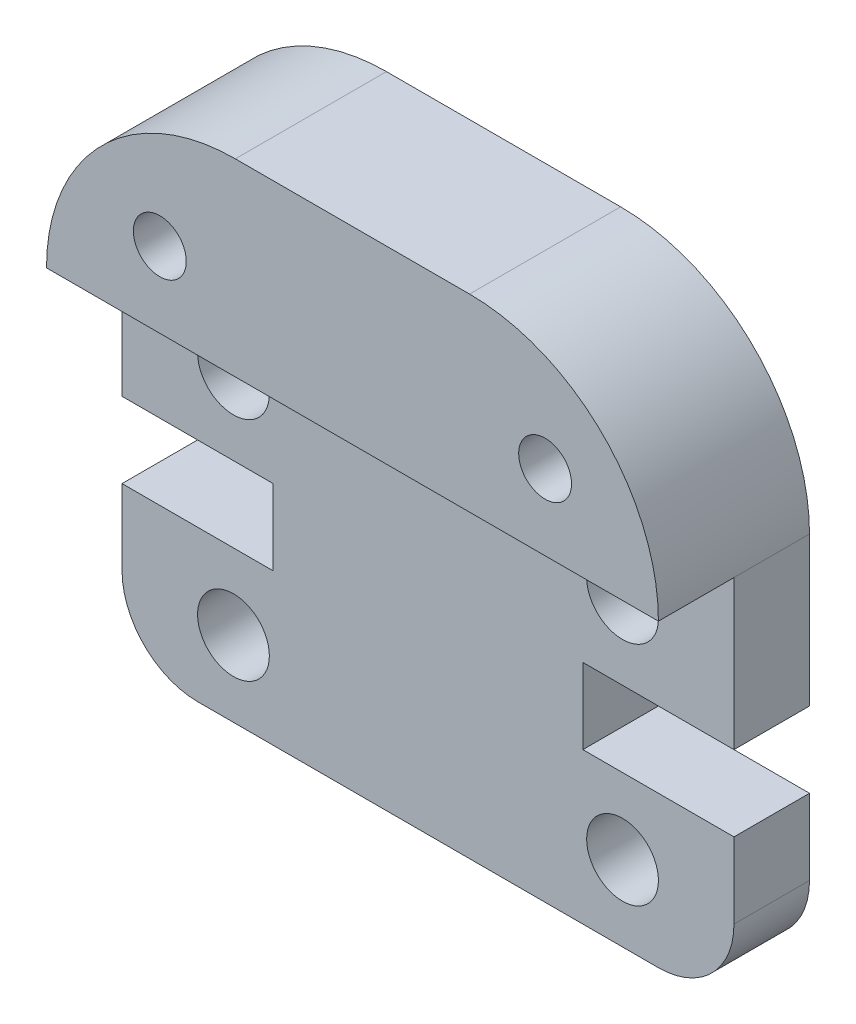
from build123d import *

# Parameters (mm, degrees)
SKETCH2_R           = 0.95
SKETCH2_R_2         = 0.7
BOSS_EXTRUDE1_DEPTH = 4
SKETCH3_W           = 16.2
SKETCH3_H           = 9.945
CUT_EXTRUDE2_DEPTH  = 2


with BuildPart() as part:
    # Sketch2 → Boss-Extrude1 (new body)
    with BuildSketch(Plane.XY):
        with BuildLine():
            Line((0, 9.945), (0, 6))
            Line((0, 6), (4, 6))
            Line((4, 6), (4, 4))
            Line((4, 4), (0, 4))
            Line((0, 4), (0, 2))
            ThreePointArc((0, 2), (0.585786438, 0.585786438), (2, 0))
            Line((2, 0), (14.2, 0))
            ThreePointArc((14.2, 0), (15.614213562, 0.585786438), (16.2, 2))
            Line((16.2, 2), (16.2, 4))
            Line((16.2, 4), (12.2, 4))
            Line((12.2, 4), (12.2, 6))
            Line((12.2, 6), (16.2, 6))
            Line((16.2, 6), (16.2, 9.945))
            ThreePointArc((16.2, 9.945), (14.735533906, 13.480533906), (11.2, 14.945))
            Line((11.2, 14.945), (5, 14.945))
            ThreePointArc((5, 14.945), (1.464466094, 13.480533906), (0, 9.945))
        make_face()
        with Locations((13.25, 8)):
            Circle(SKETCH2_R, mode=Mode.SUBTRACT)
        with Locations((13.25, 2)):
            Circle(SKETCH2_R, mode=Mode.SUBTRACT)
        with Locations((13.2, 11.942)):
            Circle(SKETCH2_R_2, mode=Mode.SUBTRACT)
        with Locations((3, 11.942)):
            Circle(SKETCH2_R_2, mode=Mode.SUBTRACT)
        with Locations((2.95, 2)):
            Circle(SKETCH2_R, mode=Mode.SUBTRACT)
        with Locations((2.95, 8)):
            Circle(SKETCH2_R, mode=Mode.SUBTRACT)
    extrude(amount=BOSS_EXTRUDE1_DEPTH)

    # Sketch3 → Cut-Extrude2 (cut)
    with BuildSketch(Plane(origin=(0, 0, 4), x_dir=(-1, 0, 0), z_dir=(0, 0, -1))):
        with Locations((-8.1, 4.9725)):
            Rectangle(SKETCH3_W, SKETCH3_H)
    extrude(amount=CUT_EXTRUDE2_DEPTH, mode=Mode.SUBTRACT)


solid = part.part
